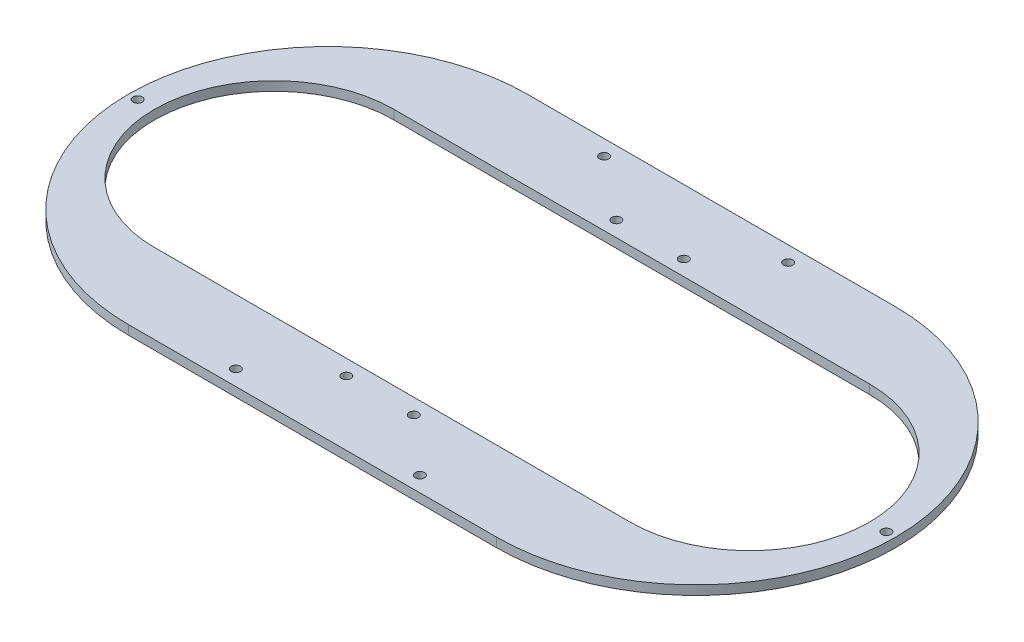
from build123d import *

# Parameters (mm, degrees)
SKETCH_1_R          = 1.5
EXTRUDE_2_DEPTH     = 3
SKETCH_2_R          = 1.5
CUT_EXTRUDE_1_DEPTH = 10
CUT_EXTRUDE_2_DEPTH = 10


with BuildPart() as part:
    # 草图1 → 凸台-拉伸2 (new body)
    with BuildSketch(Plane(origin=(0, 0, 0), x_dir=(1, 0, 0), z_dir=(0, 1, 0))):
        with BuildLine():
            Line((-60, 65), (60, 65))
            ThreePointArc((60, 65), (125, 0), (60, -65))
            Line((60, -65), (-60, -65))
            ThreePointArc((-60, -65), (-125, 0), (-60, 65))
        make_face()
        with Locations((-122, 0)):
            Circle(SKETCH_1_R, mode=Mode.SUBTRACT)
        with Locations((122, 0)):
            Circle(SKETCH_1_R, mode=Mode.SUBTRACT)
        with Locations((-30, 60)):
            Circle(SKETCH_1_R, mode=Mode.SUBTRACT)
        with Locations((30, 60)):
            Circle(SKETCH_1_R, mode=Mode.SUBTRACT)
        with Locations((30, -60)):
            Circle(SKETCH_1_R, mode=Mode.SUBTRACT)
        with Locations((-30, -60)):
            Circle(SKETCH_1_R, mode=Mode.SUBTRACT)
    extrude(amount=EXTRUDE_2_DEPTH)

    # 草图2 → 切除-拉伸1 (cut)
    with BuildSketch(Plane(origin=(0, 3, 0), x_dir=(1, 0, 0), z_dir=(0, 1, 0))):
        with Locations((-10, 44)):
            Circle(SKETCH_2_R)
        with Locations((12, 44)):
            Circle(SKETCH_2_R)
        with Locations((-10, -44)):
            Circle(SKETCH_2_R)
        with Locations((12, -44)):
            Circle(SKETCH_2_R)
    extrude(amount=-CUT_EXTRUDE_1_DEPTH, mode=Mode.SUBTRACT)

    # 草图3 → 切除-拉伸2 (cut)
    with BuildSketch(Plane(origin=(0, 3, 0), x_dir=(1, 0, 0), z_dir=(0, 1, 0))):
        with BuildLine():
            Line((-77.5, 39), (77.5, 39))
            ThreePointArc((77.5, 39), (116.5, 0), (77.5, -39))
            Line((77.5, -39), (-77.5, -39))
            ThreePointArc((-77.5, -39), (-116.5, 0), (-77.5, 39))
        make_face()
    extrude(amount=-CUT_EXTRUDE_2_DEPTH, mode=Mode.SUBTRACT)


solid = part.part
